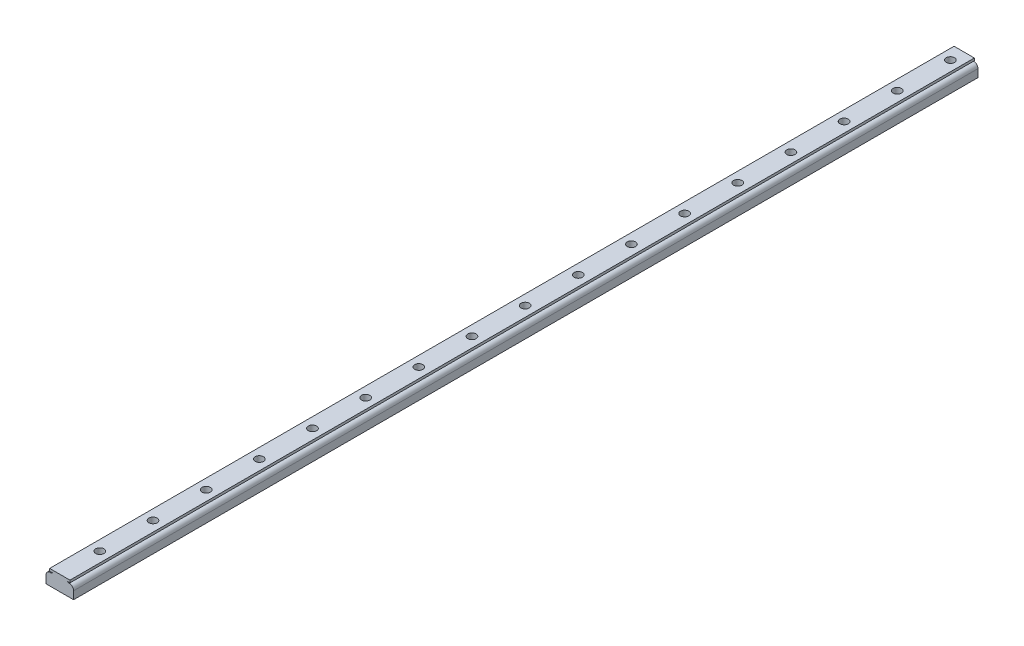
from build123d import *

# Parameters (mm, degrees)
SALIENTE_EXTRUIR1_DEPTH = 655
CROQUIS2_R              = 3
CORTAR_EXTRUIR1_DEPTH   = 12


with BuildPart() as part:
    # Croquis1 → Saliente-Extruir1 (new body)
    with BuildSketch(Plane.XY):
        with BuildLine():
            Line((-10, 0), (-10, 5.656056356))
            ThreePointArc((-10, 5.656056356), (-8.921539569, 7.959897862), (-6.461542876, 8.607338099))
            Line((-6.461542876, 8.607338099), (-5.221744043, 9.236902282))
            Line((-5.221744043, 9.236902282), (-7.354818693, 9.236902282))
            Line((-7.354818693, 9.236902282), (-7.354818693, 11))
            Line((-7.354818693, 11), (7.354818693, 11))
            Line((7.354818693, 11), (7.354818693, 9.236902282))
            Line((7.354818693, 9.236902282), (5.221744043, 9.236902282))
            Line((5.221744043, 9.236902282), (6.461542876, 8.607338099))
            ThreePointArc((6.461542876, 8.607338099), (8.921539569, 7.959897862), (10, 5.656056356))
            Line((10, 5.656056356), (10, 0))
            Line((10, 0), (0, 0))
            Line((0, 0), (-10, 0))
        make_face()
    extrude(amount=SALIENTE_EXTRUIR1_DEPTH)

    # Croquis2 → Cortar-Extruir1 (cut)
    with BuildSketch(Plane(origin=(0, 11, 0), x_dir=(1, 0, 0), z_dir=(0, 1, 0))):
        with Locations((0, -10)):
            Circle(CROQUIS2_R)
        with Locations((0, -48.5)):
            Circle(CROQUIS2_R)
        with Locations((0, -87)):
            Circle(CROQUIS2_R)
        with Locations((0, -125.5)):
            Circle(CROQUIS2_R)
        with Locations((0, -164)):
            Circle(CROQUIS2_R)
        with Locations((0, -202.5)):
            Circle(CROQUIS2_R)
        with Locations((0, -241)):
            Circle(CROQUIS2_R)
        with Locations((0, -279.5)):
            Circle(CROQUIS2_R)
        with Locations((0, -318)):
            Circle(CROQUIS2_R)
        with Locations((0, -356.5)):
            Circle(CROQUIS2_R)
        with Locations((0, -395)):
            Circle(CROQUIS2_R)
        with Locations((0, -433.5)):
            Circle(CROQUIS2_R)
        with Locations((0, -472)):
            Circle(CROQUIS2_R)
        with Locations((0, -510.5)):
            Circle(CROQUIS2_R)
        with Locations((0, -549)):
            Circle(CROQUIS2_R)
        with Locations((0, -587.5)):
            Circle(CROQUIS2_R)
        with Locations((0, -626)):
            Circle(CROQUIS2_R)
    extrude(amount=-CORTAR_EXTRUIR1_DEPTH, mode=Mode.SUBTRACT)


solid = part.part
